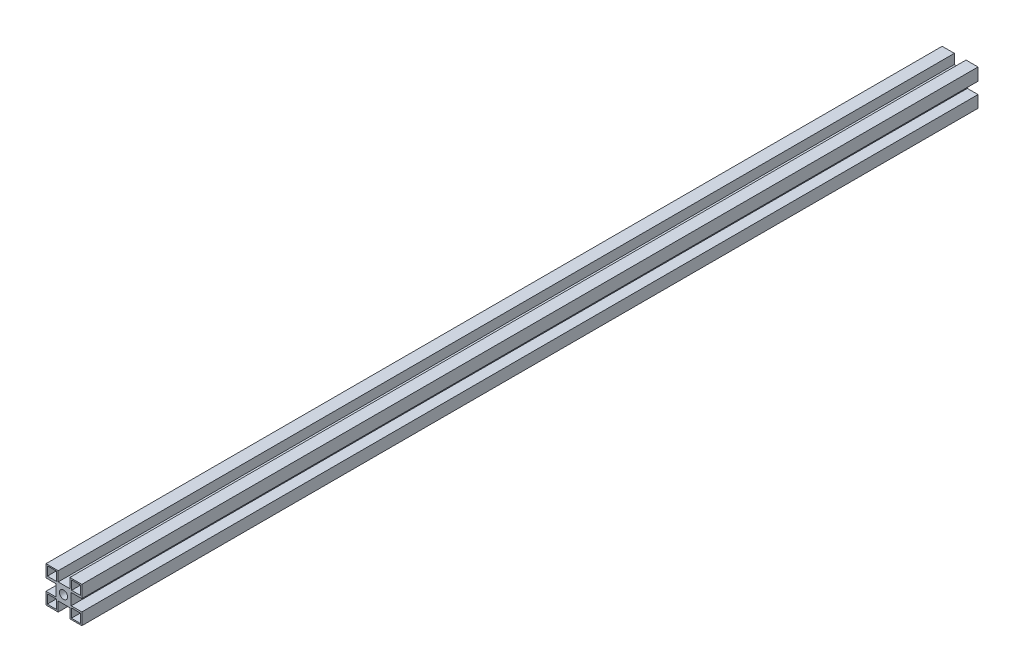
from build123d import *

# Parameters (mm, degrees)
CROQUIS1_R              = 2.270171195
CROQUIS1_W              = 5
CROQUIS1_H              = 5
SALIENTE_EXTRUIR1_DEPTH = 500


with BuildPart() as part:
    # Croquis1 → Saliente-Extruir1 (new body)
    with BuildSketch(Plane.XY):
        Polygon((-33.948638093, 23.139534884), (-27.136727468, 23.139534884), (-27.136727468, 17.716762724), (-20.630951588, 17.716762724), (-20.630951588, 23.139534884), (-13.948638093, 23.139534884), (-13.948638093, 16.236906269), (-19.879288239, 16.236906269), (-19.879288239, 9.808888666), (-13.948638093, 9.808888666), (-13.948638093, 3.139534884), (-20.630951588, 3.139534884), (-20.630951588, 8.512917375), (-27.136727468, 8.512917375), (-27.136727468, 3.139534884), (-33.948638093, 3.139534884), (-33.948638093, 9.808888666), (-28.435147943, 9.808888666), (-28.435147943, 16.236906269), (-33.948638093, 16.236906269), align=None)
        with Locations((-24.190567421, 13.071873519)):
            Circle(CROQUIS1_R, mode=Mode.SUBTRACT)
        with Locations((-17.14132598, 19.908919202)):
            Rectangle(CROQUIS1_W, CROQUIS1_H, mode=Mode.SUBTRACT)
        with Locations((-30.687316761, 19.989458432)):
            Rectangle(CROQUIS1_W, CROQUIS1_H, mode=Mode.SUBTRACT)
        with Locations((-17.280419986, 6.358743426)):
            Rectangle(CROQUIS1_W, CROQUIS1_H, mode=Mode.SUBTRACT)
        with Locations((-30.724971308, 6.451680119)):
            Rectangle(CROQUIS1_W, CROQUIS1_H, mode=Mode.SUBTRACT)
    extrude(amount=SALIENTE_EXTRUIR1_DEPTH)


solid = part.part
